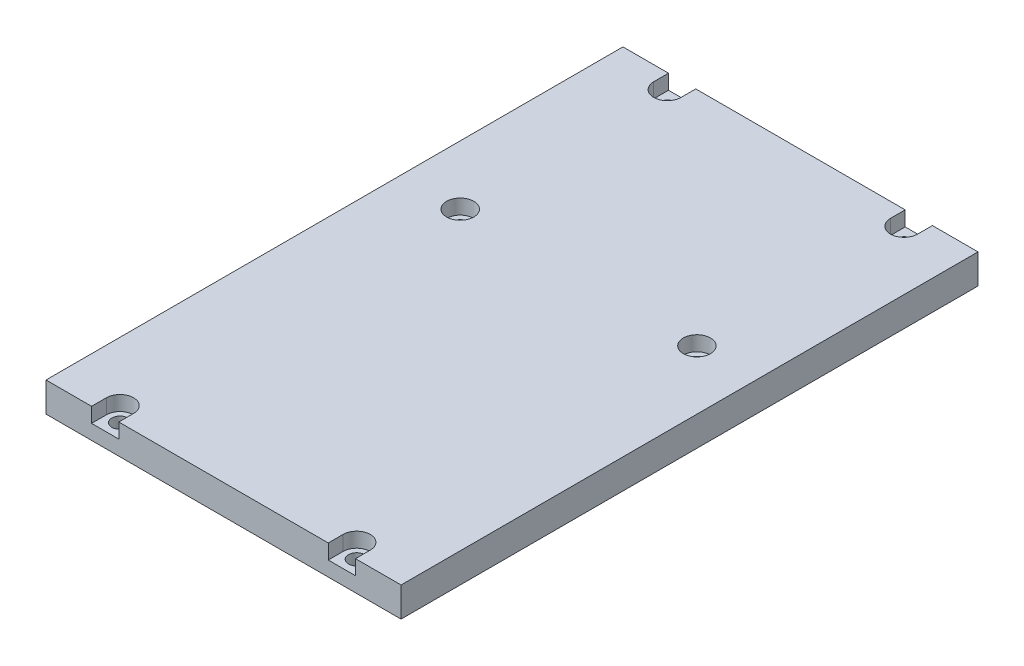
from build123d import *

# Parameters (mm, degrees)
SKETCH1_W           = 120
SKETCH1_H           = 195
BOSS_EXTRUDE1_DEPTH = 10
SKETCH2_R           = 2.75
CUT_EXTRUDE1_DEPTH  = 11
SKETCH3_R           = 4.6
CUT_EXTRUDE2_DEPTH  = 5


with BuildPart() as part:
    # Sketch1 → Boss-Extrude1 (new body)
    with BuildSketch(Plane(origin=(0, 0, 0), x_dir=(1, 0, 0), z_dir=(0, 1, 0))):
        with Locations((-17.427799272, -26.251292201)):
            Rectangle(SKETCH1_W, SKETCH1_H)
    extrude(amount=BOSS_EXTRUDE1_DEPTH)

    # Sketch2 → Cut-Extrude1 (cut, through all)
    with BuildSketch(Plane(origin=(0, 10, 0), x_dir=(-1, 0, 0), z_dir=(0, 1, 0))):
        with Locations((-22.572200728, 118.751292201)):
            Circle(SKETCH2_R)
        with Locations((57.427799272, 118.751292201)):
            Circle(SKETCH2_R)
        with Locations((-22.572200728, 3.751292201)):
            Circle(SKETCH2_R)
        with Locations((57.427799272, 3.751292201)):
            Circle(SKETCH2_R)
        with Locations((-22.572200728, -66.248707799)):
            Circle(SKETCH2_R)
        with Locations((57.427799272, -66.248707799)):
            Circle(SKETCH2_R)
    extrude(amount=-CUT_EXTRUDE1_DEPTH, mode=Mode.SUBTRACT)

    # Sketch3 → Cut-Extrude2 (cut)
    with BuildSketch(Plane(origin=(0, 10, 0), x_dir=(1, 0, 0), z_dir=(0, 1, 0))):
        with Locations((22.572200728, -3.751292201)):
            Circle(SKETCH3_R)
        with Locations((-57.427799272, -3.751292201)):
            Circle(SKETCH3_R)
        with BuildLine():
            Line((-62.027799272, 66.248707799), (-62.027799272, 71.248707799))
            Line((-62.027799272, 71.248707799), (-52.827799272, 71.248707799))
            Line((-52.827799272, 71.248707799), (-52.827799272, 66.248707799))
            ThreePointArc((-52.827799272, 66.248707799), (-57.427799272, 61.648707799), (-62.027799272, 66.248707799))
        make_face()
        with BuildLine():
            Line((17.972200728, 66.248707799), (17.972200728, 71.248707799))
            Line((17.972200728, 71.248707799), (27.172200728, 71.248707799))
            Line((27.172200728, 71.248707799), (27.172200728, 66.248707799))
            ThreePointArc((27.172200728, 66.248707799), (22.572200728, 61.648707799), (17.972200728, 66.248707799))
        make_face()
        with BuildLine():
            Line((-62.027799272, -118.751292201), (-62.027799272, -123.751292201))
            Line((-62.027799272, -123.751292201), (-52.827799272, -123.751292201))
            Line((-52.827799272, -123.751292201), (-52.827799272, -118.751292201))
            ThreePointArc((-52.827799272, -118.751292201), (-57.427799272, -114.151292201), (-62.027799272, -118.751292201))
        make_face()
        with BuildLine():
            Line((17.972200728, -118.751292201), (17.972200728, -123.751292201))
            Line((17.972200728, -123.751292201), (27.172200728, -123.751292201))
            Line((27.172200728, -123.751292201), (27.172200728, -118.751292201))
            ThreePointArc((27.172200728, -118.751292201), (22.572200728, -114.151292201), (17.972200728, -118.751292201))
        make_face()
    extrude(amount=-CUT_EXTRUDE2_DEPTH, mode=Mode.SUBTRACT)


solid = part.part
